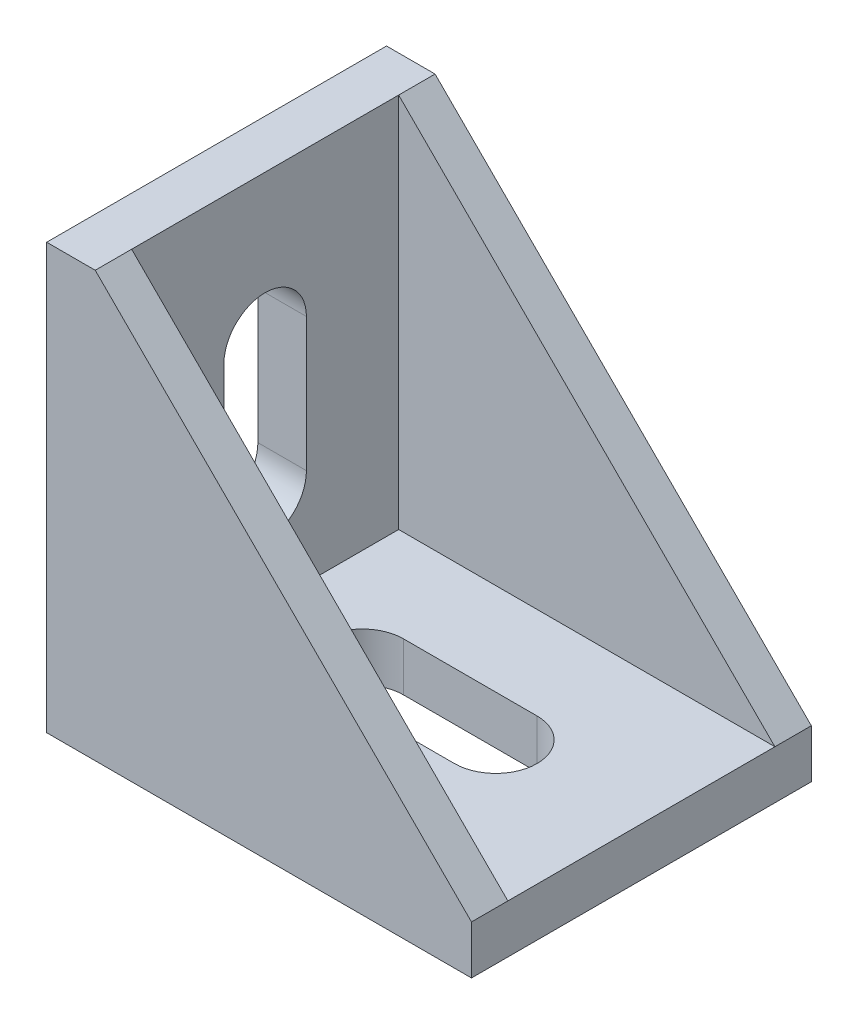
from build123d import *

# Parameters (mm, degrees)
EXTRUDE_1_DEPTH     = 14
EXTRUDE_2_DEPTH     = 3
CUT_EXTRUDE_1_DEPTH = 5
SKETCH_4_W          = 2.5
SKETCH_4_H          = 8
EXTRUDE_3_DEPTH     = 2.5


with BuildPart() as part:
    # Эскиз1 → Бобышка-Вытянуть1 (new body, symmetric)
    with BuildSketch(Plane.XY):
        Polygon((0, 35), (0, 0), (35, 0), (35, 4), (4, 4), (4, 35), align=None)
    extrude(amount=EXTRUDE_1_DEPTH, both=True)

    # Эскиз2 → Бобышка-Вытянуть2 (add)
    with BuildSketch(Plane.XY.offset(14)):
        Polygon((4, 35), (35, 4), (4, 4), align=None)
    extrude_2 = extrude(amount=-EXTRUDE_2_DEPTH)

    # Зеркальное отражение2: Бобышка-Вытянуть2 across plane
    add(extrude_2.mirror(Plane.XY))

    # Эскиз3 → Вырез-Вытянуть1 (cut, through all)
    with BuildSketch(Plane(origin=(0, 4, 0), x_dir=(1, 0, 0), z_dir=(0, 1, 0))):
        with BuildLine():
            Line((12, 3.4), (23, 3.4))
            ThreePointArc((23, 3.4), (26.4, 0), (23, -3.4))
            Line((23, -3.4), (12, -3.4))
            ThreePointArc((12, -3.4), (8.6, 0), (12, 3.4))
        make_face()
    cut_extrude_1 = extrude(amount=-CUT_EXTRUDE_1_DEPTH, mode=Mode.SUBTRACT)

    # Эскиз4 → Бобышка-Вытянуть3 (add)
    with BuildSketch(Plane.XZ):
        with Locations((4.25, 0)):
            Rectangle(SKETCH_4_W, SKETCH_4_H)
        with Locations((30.75, 0)):
            Rectangle(SKETCH_4_W, SKETCH_4_H)
    extrude_3 = extrude(amount=EXTRUDE_3_DEPTH)

    # Зеркальное отражение3: Вырез-Вытянуть1, Бобышка-Вытянуть3 across plane
    add(cut_extrude_1.mirror(Plane(origin=(0, 0, 0), x_dir=(0, 0, 1), z_dir=(-0.707106781, 0.707106781, 0))), mode=Mode.SUBTRACT)
    add(extrude_3.mirror(Plane(origin=(0, 0, 0), x_dir=(0, 0, 1), z_dir=(-0.707106781, 0.707106781, 0))))


solid = part.part
